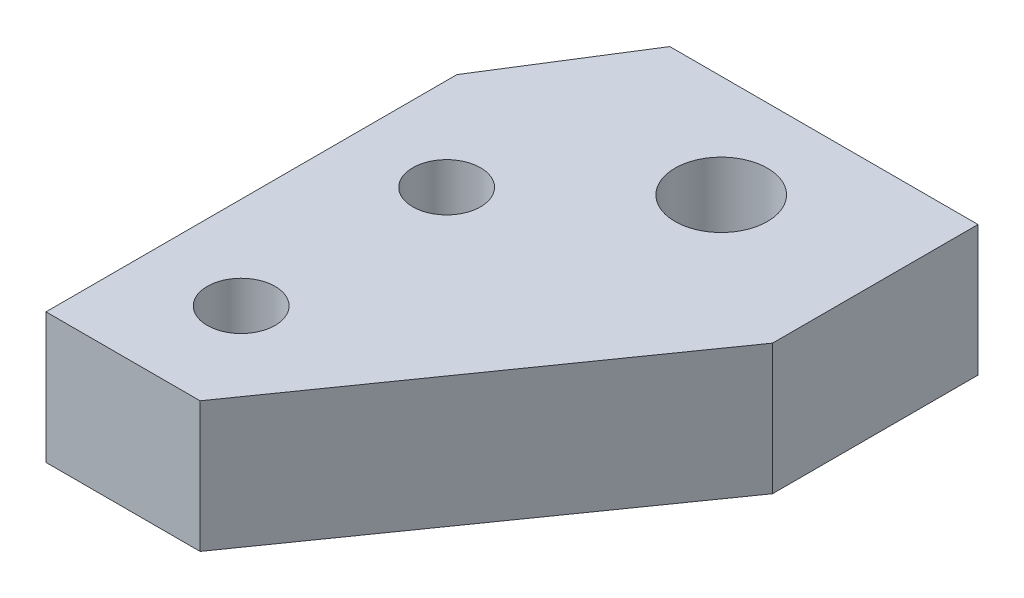
from build123d import *

# Parameters (mm, degrees)
BOSS_EXTRUDE1_DEPTH   = 3.175
M4X0_7_TAPPED_HOLE1_D = 3.3
M4_CLEARANCE_HOLE1_D  = 4.5


with BuildPart() as part:
    # Sketch1 → Boss-Extrude1 (new body, symmetric)
    with BuildSketch(Plane(origin=(0, 0, 0), x_dir=(1, 0, 0), z_dir=(0, 1, 0))):
        Polygon((0, 0), (0, 20), (4, 26.363068172), (19, 26.363068172), (19, 16.363068172), (7.5, 0), align=None)
    extrude(amount=BOSS_EXTRUDE1_DEPTH, both=True)

    # M4x0.7 Tapped Hole1 (through all)
    with Locations(Plane(origin=(0, 3.175, 0), x_dir=(1, 0, 0), z_dir=(0, 1, 0))):
        with Locations((4.499999553, 15), (4.499999553, 5)):
            Hole(M4X0_7_TAPPED_HOLE1_D / 2)

    # M4 Clearance Hole1 (through all)
    with Locations(Plane(origin=(0, 3.175, 0), x_dir=(1, 0, 0), z_dir=(0, 1, 0))):
        with Locations((11.5, 21.364471274)):
            Hole(M4_CLEARANCE_HOLE1_D / 2)


solid = part.part
